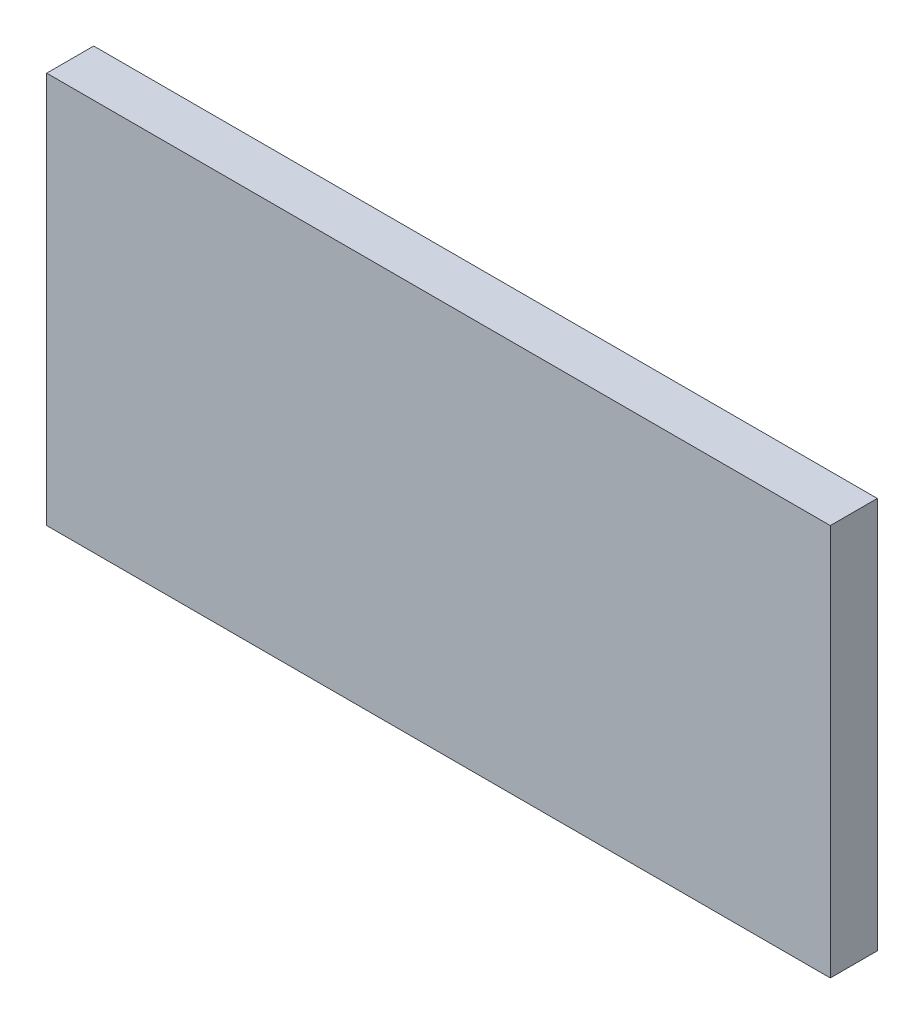
from build123d import *

# Parameters (mm, degrees)
SKETCH1_W           = 100
SKETCH1_H           = 50
BOSS_EXTRUDE1_DEPTH = 6


with BuildPart() as part:
    # Sketch1 → Boss-Extrude1 (new body)
    with BuildSketch(Plane.XY):
        with Locations((45.675105485, 23.217299578)):
            Rectangle(SKETCH1_W, SKETCH1_H)
    extrude(amount=BOSS_EXTRUDE1_DEPTH)


solid = part.part
